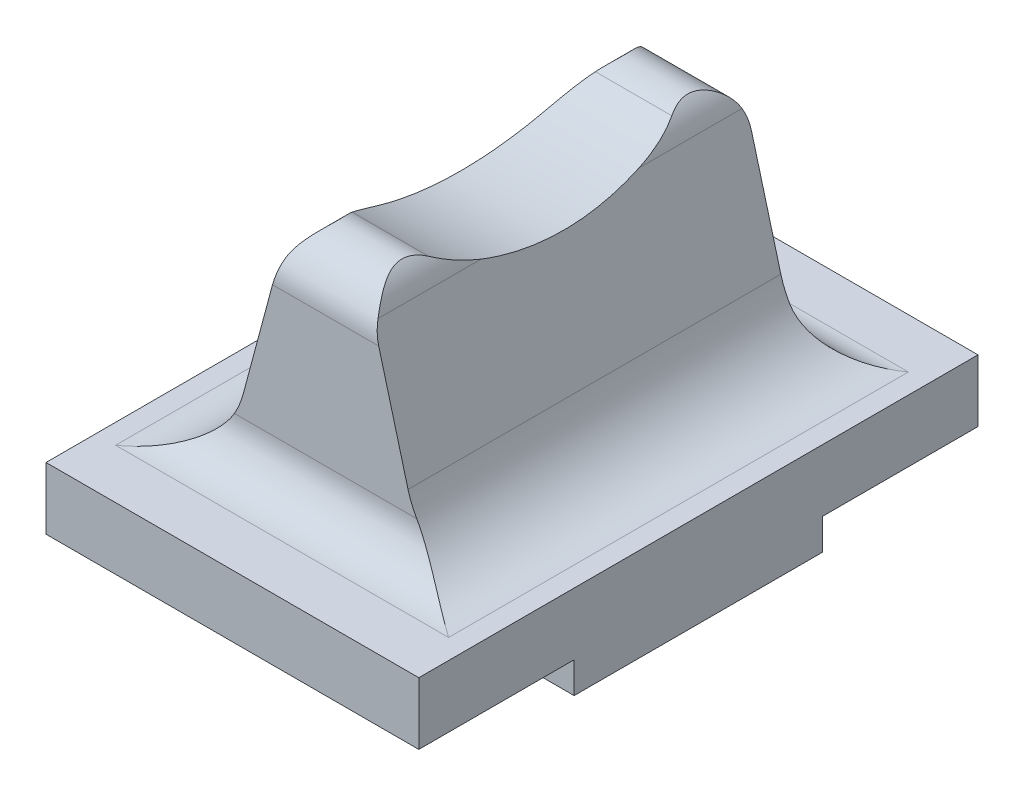
from build123d import *

# Parameters (mm, degrees)
BOSS_EXTRUDE1_DEPTH = 30
BOSS_EXTRUDE2_DEPTH = 30
FILLET1_R           = 7
CUT_EXTRUDE1_DEPTH  = 91


with BuildPart() as part:
    # Sketch1 → Boss-Extrude1 (new body, symmetric)
    with BuildSketch(Plane(origin=(0, 0, 0), x_dir=(0, 0, -1), z_dir=(1, 0, 0))):
        Polygon((-20, 0), (20, 0), (20, 5), (45, 5), (45, 15), (-45, 15), (-45, 5), (-20, 5), align=None)
    extrude(amount=BOSS_EXTRUDE1_DEPTH, both=True)

    # Sketch4 → Boss-Extrude2 (add, symmetric)
    with BuildSketch(Plane(origin=(0, 0, 0), x_dir=(0, 0, -1), z_dir=(1, 0, 0))):
        with BuildLine():
            Line((30, 15), (30, 43))
            ThreePointArc((30, 43), (26.537038068, 49.040642491), (19.574468085, 49.104566414))
            ThreePointArc((19.574468085, 49.104566414), (0, 43.987803064), (-19.574468085, 49.104566414))
            ThreePointArc((-19.574468085, 49.104566414), (-26.537038068, 49.040642491), (-30, 43))
            Line((-30, 43), (-30, 15))
            Line((-30, 15), (30, 15))
        make_face()
    extrude(amount=BOSS_EXTRUDE2_DEPTH, both=True)

    # Fillet1
    fillet1_edges = [part.edges().sort_by_distance(p)[0] for p in [
        (0, 15, 30),
        (0, 15, -30),
    ]]
    fillet(fillet1_edges, radius=FILLET1_R)

    # Sketch5 → Cut-Extrude1 (cut, through all)
    with BuildSketch(Plane.XY.offset(45)):
        with BuildLine():
            ThreePointArc((-7.72740661, 46.058355425), (-6.794626723, 48.210722397), (-5.277640382, 50))
            Line((-5.277640382, 50), (-30, 50))
            Line((-30, 50), (-30, 15))
            Line((-30, 15), (-26.792045696, 15))
            ThreePointArc((-26.792045696, 15), (-18.26938569, 17.893053236), (-13.269084128, 25.376533369))
            Line((-13.269084128, 25.376533369), (-7.72740661, 46.058355425))
        make_face()
        with BuildLine():
            ThreePointArc((5.277640382, 50), (6.794626723, 48.210722397), (7.72740661, 46.058355425))
            Line((7.72740661, 46.058355425), (13.269084128, 25.376533369))
            ThreePointArc((13.269084128, 25.376533369), (18.26938569, 17.893053236), (26.792045696, 15))
            Line((26.792045696, 15), (30, 15))
            Line((30, 15), (30, 50))
            Line((30, 50), (5.277640382, 50))
        make_face()
    extrude(amount=-CUT_EXTRUDE1_DEPTH, mode=Mode.SUBTRACT)


solid = part.part
